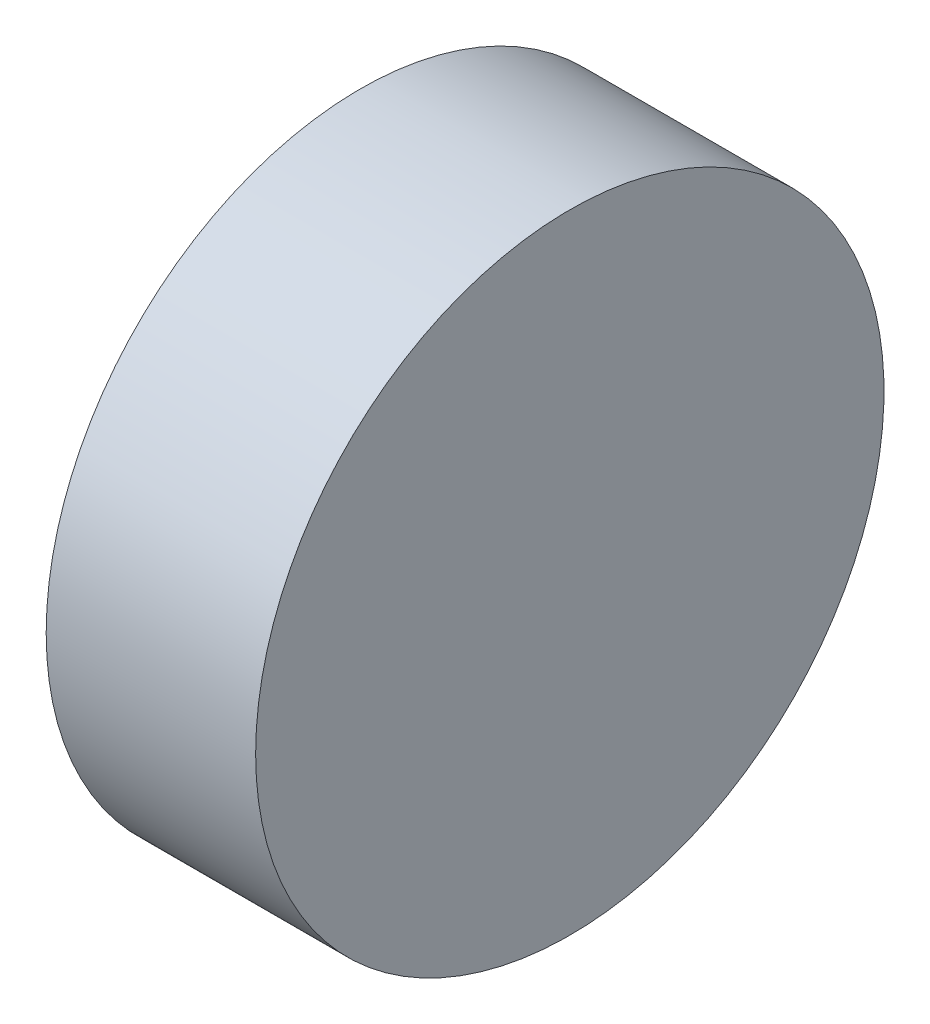
from build123d import *

# Parameters (mm, degrees)
SKETCH_1_W = 10
SKETCH_1_H = 15


with BuildPart() as part:
    # 草图1 → 旋转1 (revolve)
    with BuildSketch(Plane.XY, mode=Mode.PRIVATE) as revolve_1_sk:
        with Locations((265.116303666, 84.793179349)):
            Rectangle(SKETCH_1_W, SKETCH_1_H)
    revolve(revolve_1_sk.sketch.rotate(Axis((254.000801993, 77.293179349, 0), (1, 0, 0)), 90), axis=Axis((254.000801993, 77.293179349, 0), (1, 0, 0)))  # turned: the seam where the file's is


solid = part.part
